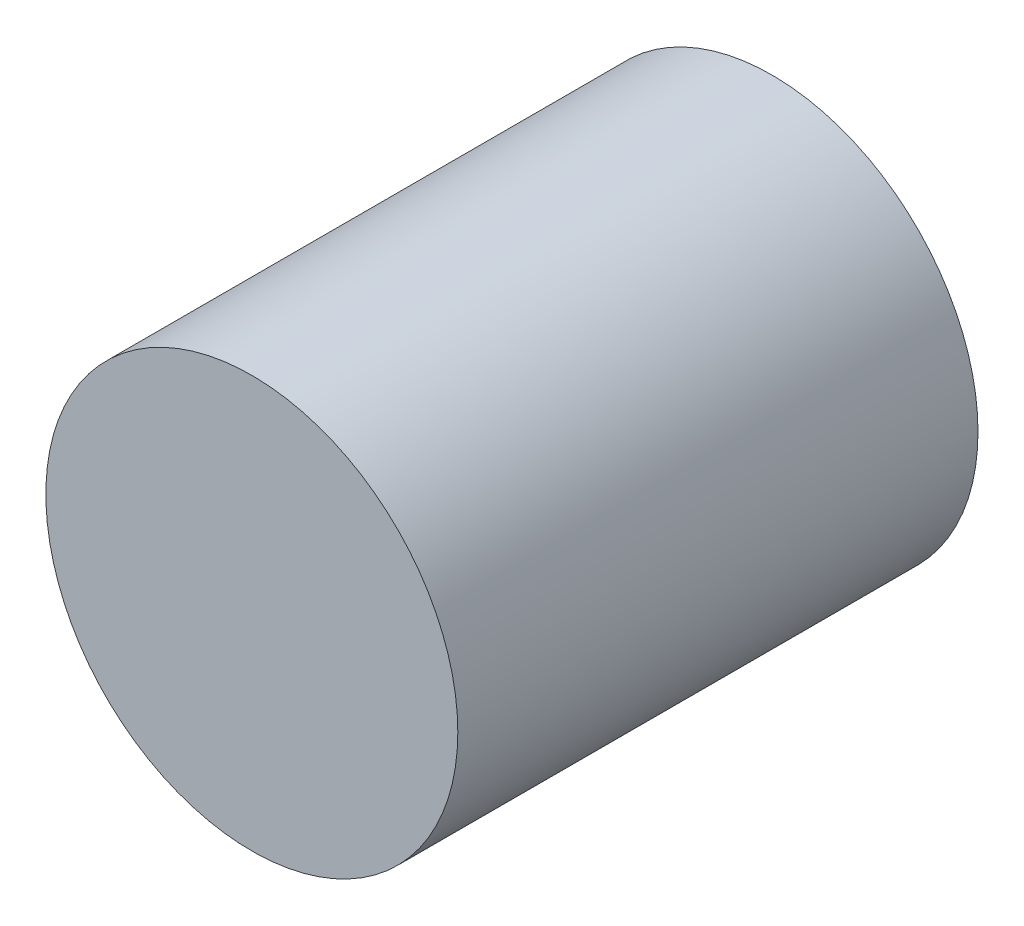
from build123d import *

# Parameters (mm, degrees)
SKETCH1_R           = 7.92
BOSS_EXTRUDE1_DEPTH = 20


with BuildPart() as part:
    # Sketch1 → Boss-Extrude1 (new body)
    with BuildSketch(Plane.XY):
        Circle(SKETCH1_R)
    extrude(amount=BOSS_EXTRUDE1_DEPTH)


solid = part.part
